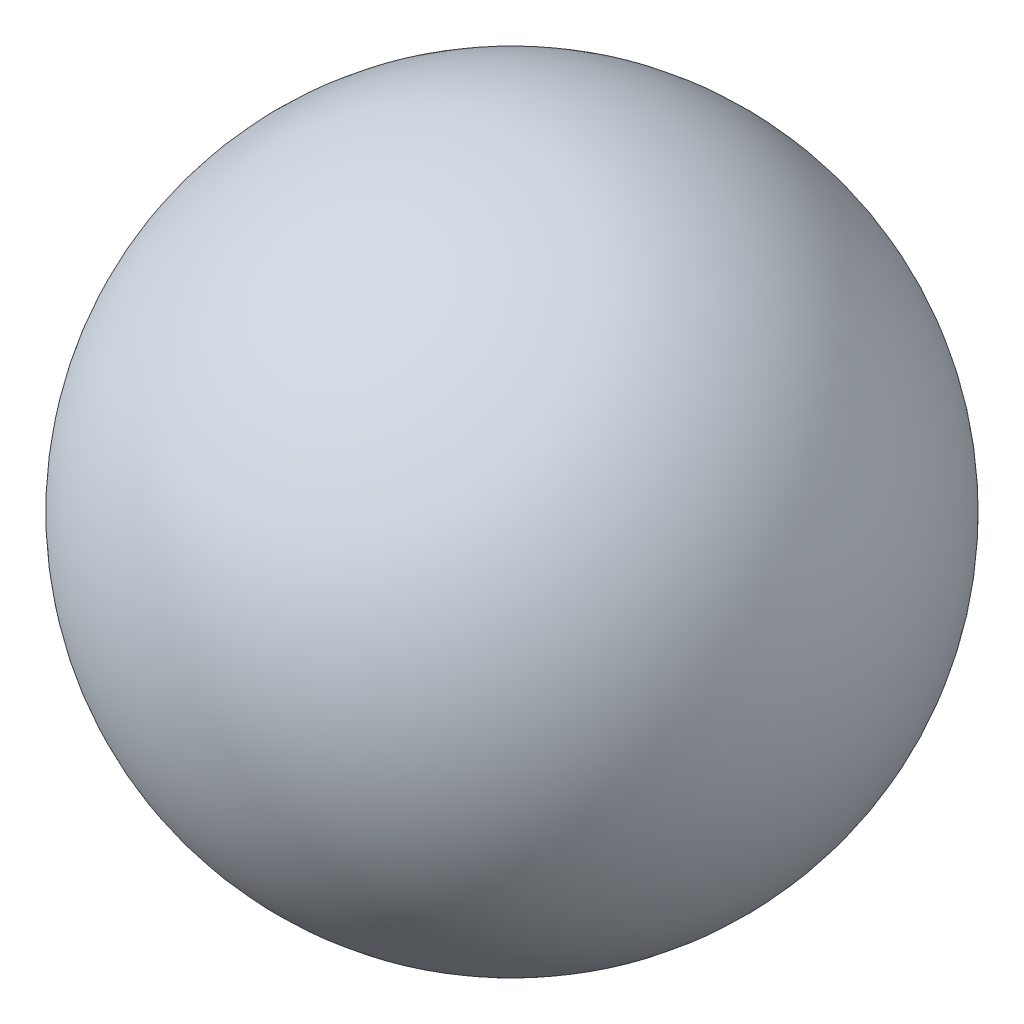
from build123d import *


with BuildPart() as part:
    # Sketch3 → Revolve1 (revolve)
    with BuildSketch(Plane.XY):
        with BuildLine():
            Line((0, 20), (0, -20))
            ThreePointArc((0, -20), (20, 0), (0, 20))
        make_face()
    revolve(axis=Axis((0, 0, 0), (0, 1, 0)))


solid = part.part
